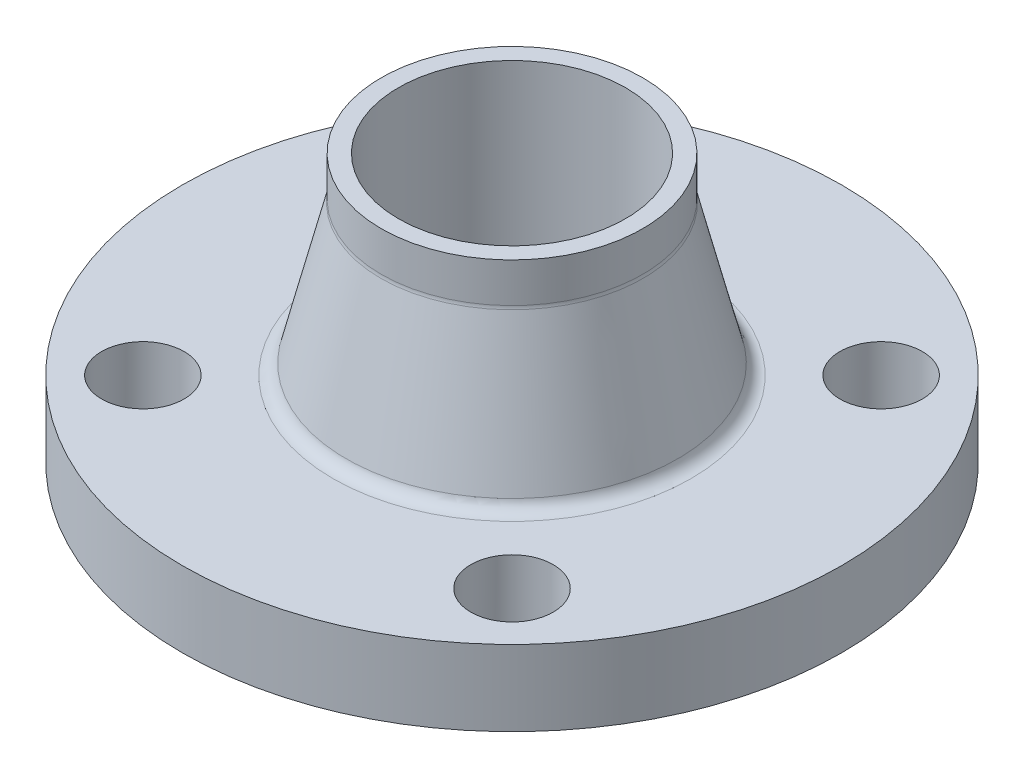
from build123d import *

# Parameters (mm, degrees)
SKETCH4_R               = 9.525
F_1ST_BOLT_HOLE_DEPTH   = 117.570504417
BOLT_HOLE_PATTERN_COUNT = 4


with BuildPart() as part:
    # Sketch3 → Base-Revolve (revolve)
    with BuildSketch(Plane.XY):
        with BuildLine():
            Line((26.2509, 61.9125), (26.2509, -1.5875))
            Line((26.2509, -1.5875), (46.0375, -1.5875))
            Line((46.0375, -1.5875), (46.0375, 0))
            Line((46.0375, 0), (76.2, 0))
            Line((76.2, 0), (76.2, 17.4625))
            Line((76.2, 17.4625), (41.377092519, 17.4625))
            ThreePointArc((41.377092519, 17.4625), (39.421017335, 18.13662118), (38.295576299, 19.872723702))
            Line((38.295576299, 19.872723702), (30.31948378, 52.010825428))
            ThreePointArc((30.31948378, 52.010825428), (30.2494576, 52.390367381), (30.226, 52.775601727))
            Line((30.226, 52.775601727), (30.226, 61.9125))
            Line((30.226, 61.9125), (26.2509, 61.9125))
        make_face()
    revolve(axis=Axis((0, 0, 0), (0, 1, 0)))

    # Sketch4 → 1st Bolt Hole (cut, through all)
    with BuildSketch(Plane(origin=(0, 17.4625, 0), x_dir=(-1, 0, 0), z_dir=(0, 1, 0))):
        with Locations((-42.656216575, 42.656216575)):
            Circle(SKETCH4_R)
    f_1st_bolt_hole = extrude(amount=-F_1ST_BOLT_HOLE_DEPTH, mode=Mode.SUBTRACT)

    # Bolt Hole Pattern: 1st Bolt Hole ×4 about axis
    bolt_hole_pattern_axis = Axis((0, 0, 0), (0, 1, 0))
    for i in range(1, BOLT_HOLE_PATTERN_COUNT):
        add(f_1st_bolt_hole.rotate(bolt_hole_pattern_axis, i * 360 / BOLT_HOLE_PATTERN_COUNT), mode=Mode.SUBTRACT)


solid = part.part
